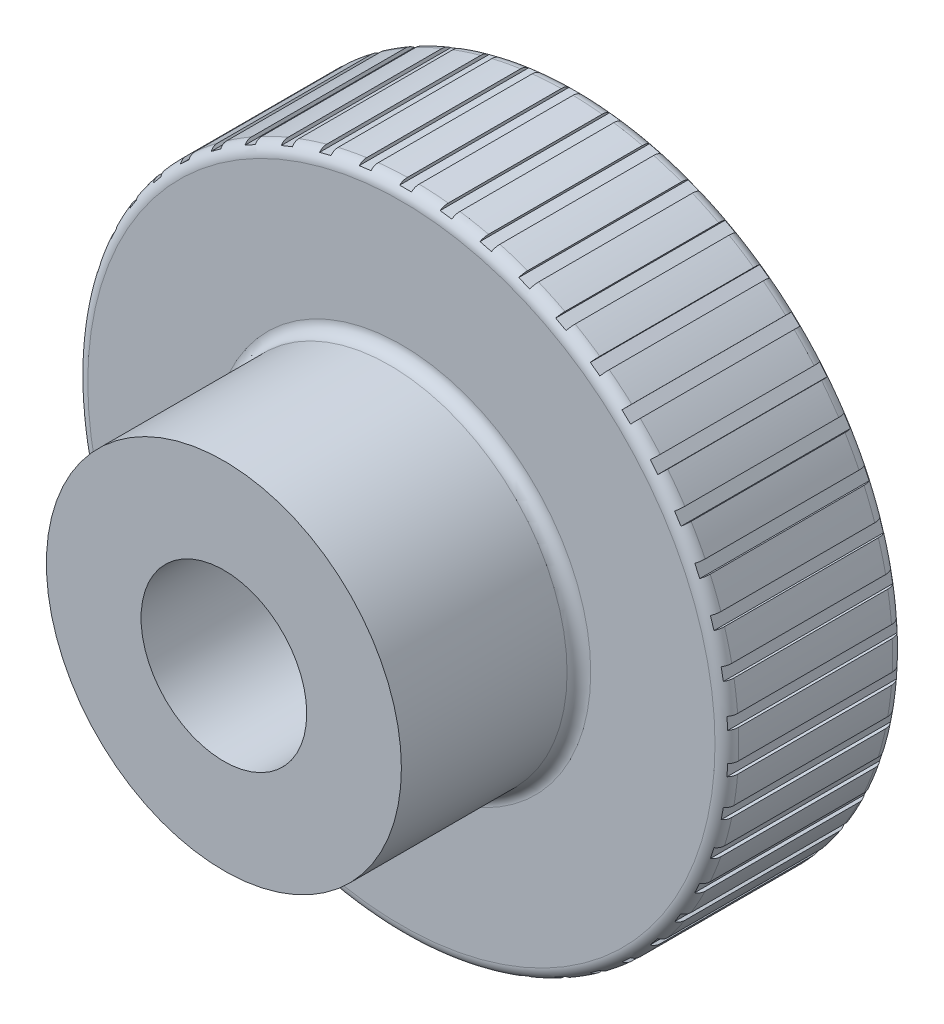
from build123d import *

# Parameters (mm, degrees)
SKETCH1_R                    = 5.5
BOSS_EXTRUDE1_DEPTH          = 3
SKETCH2_R                    = 3
BOSS_EXTRUDE2_DEPTH          = 3
M8_TAPPED_HOLE1_D            = 2.8
FILLET1_R                    = 0.2
ENL_V_MAT_EXTRU_2_DEPTH      = 10
R_P_TITION_CIRCULAIRE1_COUNT = 50


with BuildPart() as part:
    # Sketch1 → Boss-Extrude1 (new body)
    with BuildSketch(Plane.XY):
        Circle(SKETCH1_R)
    extrude(amount=BOSS_EXTRUDE1_DEPTH)

    # Sketch2 → Boss-Extrude2 (add)
    with BuildSketch(Plane.XY.offset(3)):
        Circle(SKETCH2_R)
    extrude(amount=BOSS_EXTRUDE2_DEPTH)

    # M8 Tapped Hole1 (through all)
    with Locations(Plane.XY.offset(6)):
        with Locations((0, 0)):
            Hole(M8_TAPPED_HOLE1_D / 2)

    # Fillet1
    fillet1_edges = [part.edges().sort_by_distance(p)[0] for p in [
        (-5.5, 0, 0),
        (-5.5, 0, 3),
        (-3, 0, 3),
    ]]
    fillet(fillet1_edges, radius=FILLET1_R)

    # Sketch5 → Enlèv. mat.-Extru.2 (cut)
    with BuildSketch(Plane(origin=(0, 0, 0), x_dir=(-1, 0, 0), z_dir=(0, 0, -1))):
        Polygon((-0.101399295, 5.45), (0.098600705, 5.45), (0, 11.961399684), align=None)
    enl_v_mat_extru_2 = extrude(amount=-ENL_V_MAT_EXTRU_2_DEPTH, mode=Mode.SUBTRACT)

    # Répétition circulaire1: Enlèv. mat.-Extru.2 ×50 about axis
    r_p_tition_circulaire1_axis = Axis((0, 0, 0), (0, 0, 1))
    for i in range(1, R_P_TITION_CIRCULAIRE1_COUNT):
        add(enl_v_mat_extru_2.rotate(r_p_tition_circulaire1_axis, i * 360 / R_P_TITION_CIRCULAIRE1_COUNT), mode=Mode.SUBTRACT)


solid = part.part
